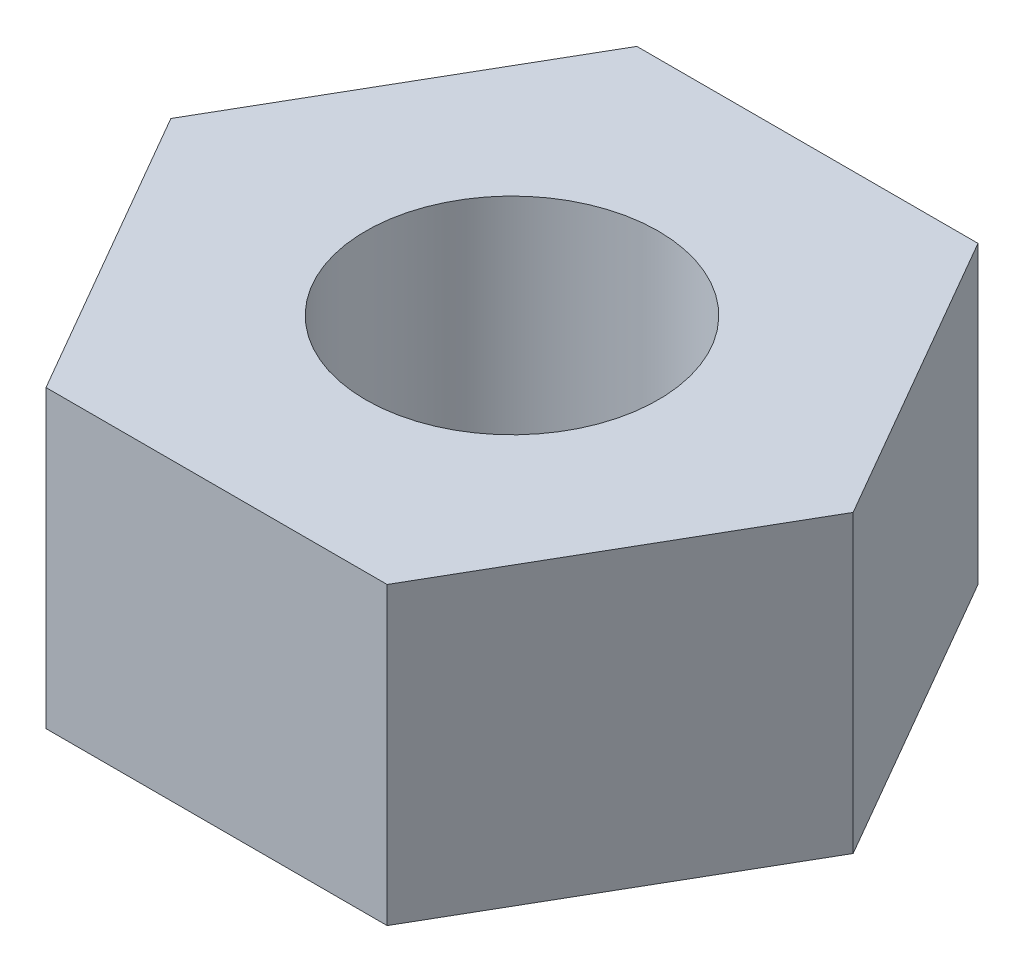
from build123d import *

# Parameters (mm, degrees)
BOSS_EXTRUDE1_DEPTH = 2
SKETCH2_R           = 0.99
CUT_EXTRUDE1_DEPTH  = 3


with BuildPart() as part:
    # Sketch1 → Boss-Extrude1 (new body)
    with BuildSketch(Plane(origin=(0, 0, 0), x_dir=(1, 0, 0), z_dir=(0, 1, 0))):
        Polygon((2.309401077, 0), (1.154700538, 2), (-1.154700538, 2), (-2.309401077, 0), (-1.154700538, -2), (1.154700538, -2), align=None)
    extrude(amount=BOSS_EXTRUDE1_DEPTH)

    # Sketch2 → Cut-Extrude1 (cut, through all)
    with BuildSketch(Plane(origin=(0, 0, 0), x_dir=(1, 0, 0), z_dir=(0, 1, 0))):
        Circle(SKETCH2_R)
    extrude(amount=CUT_EXTRUDE1_DEPTH, mode=Mode.SUBTRACT)


solid = part.part
